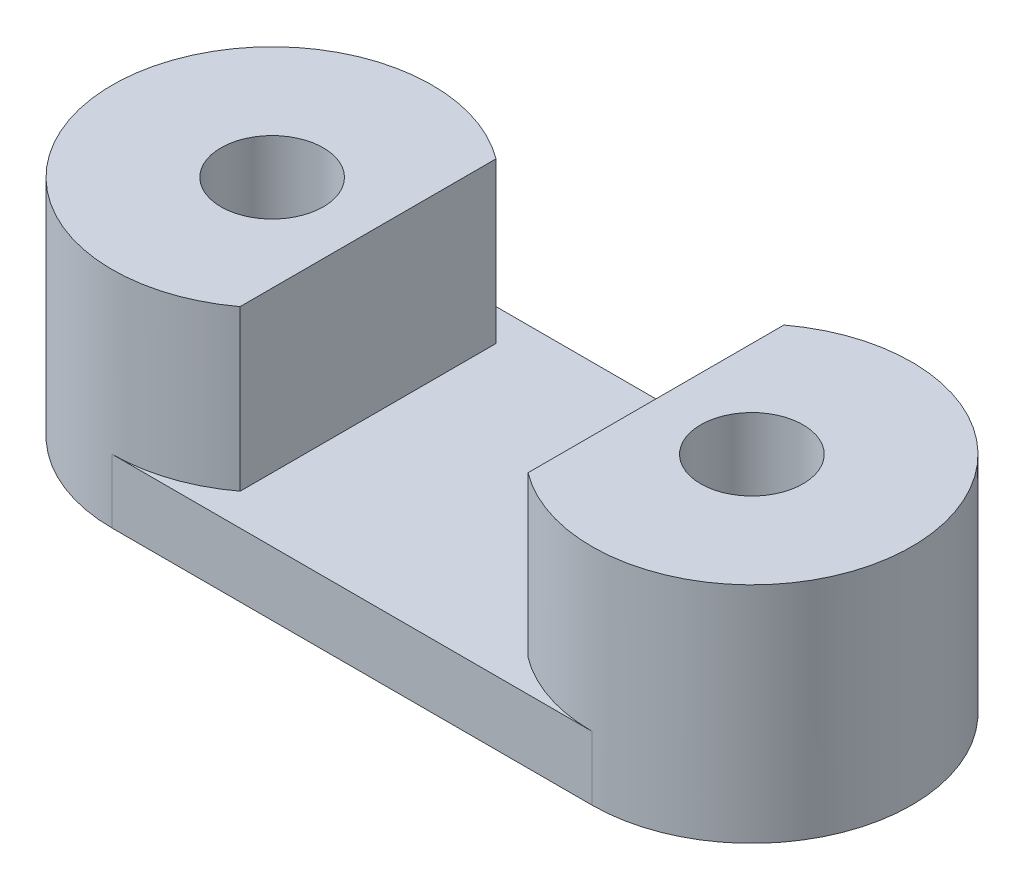
from build123d import *

# Parameters (mm, degrees)
SKETCH1_R           = 1.6
BOSS_EXTRUDE1_DEPTH = 2
SKETCH2_R           = 5
SKETCH2_R_2         = 1.6
BOSS_EXTRUDE2_DEPTH = 5
SKETCH3_W           = 9
SKETCH3_H           = 5
CUT_EXTRUDE1_DEPTH  = 11


with BuildPart() as part:
    # Sketch1 → Boss-Extrude1 (new body)
    with BuildSketch(Plane(origin=(0, 0, 0), x_dir=(1, 0, 0), z_dir=(0, 1, 0))):
        with BuildLine():
            Line((-7.5, 5), (7.5, 5))
            ThreePointArc((7.5, 5), (12.5, 0), (7.5, -5))
            Line((7.5, -5), (-7.5, -5))
            ThreePointArc((-7.5, -5), (-12.5, 0), (-7.5, 5))
        make_face()
        with Locations((-7.5, 0)):
            Circle(SKETCH1_R, mode=Mode.SUBTRACT)
        with Locations((7.5, 0)):
            Circle(SKETCH1_R, mode=Mode.SUBTRACT)
    extrude(amount=BOSS_EXTRUDE1_DEPTH)

    # Sketch2 → Boss-Extrude2 (add)
    with BuildSketch(Plane(origin=(0, 2, 0), x_dir=(1, 0, 0), z_dir=(0, 1, 0))):
        with Locations((-7.5, 0)):
            Circle(SKETCH2_R)
        with Locations((-7.5, 0)):
            Circle(SKETCH2_R_2, mode=Mode.SUBTRACT)
        with Locations((7.5, 0)):
            Circle(SKETCH2_R)
        with Locations((7.5, 0)):
            Circle(SKETCH2_R_2, mode=Mode.SUBTRACT)
    extrude(amount=BOSS_EXTRUDE2_DEPTH)

    # Sketch3 → Cut-Extrude1 (cut, through all)
    with BuildSketch(Plane.XY.offset(5)):
        with Locations((0, 4.5)):
            Rectangle(SKETCH3_W, SKETCH3_H)
    extrude(amount=-CUT_EXTRUDE1_DEPTH, mode=Mode.SUBTRACT)


solid = part.part
